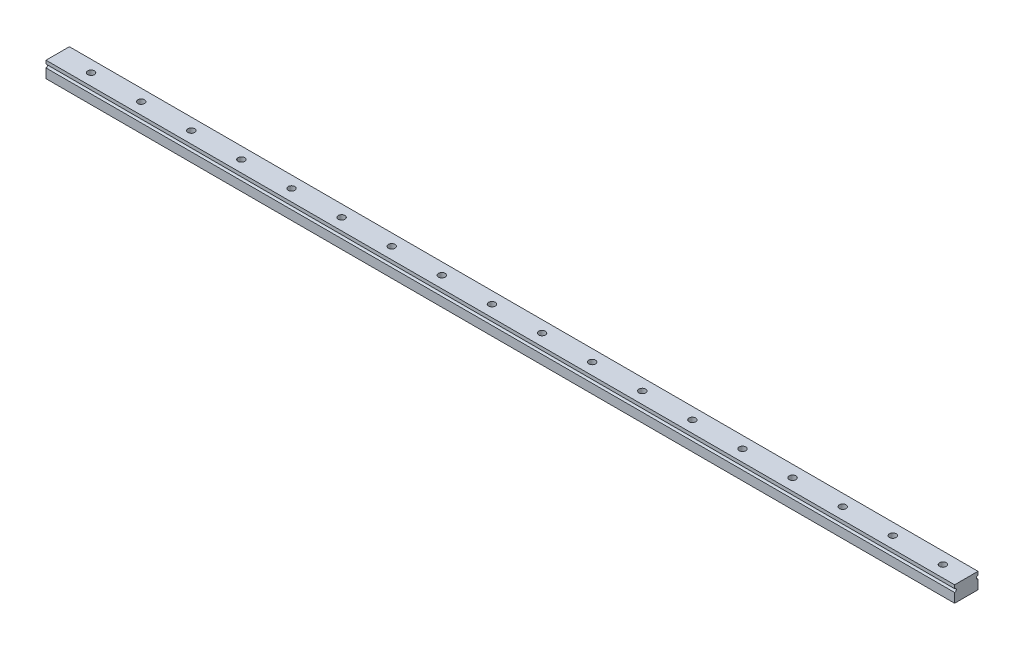
from build123d import *

# Parameters (mm, degrees)
BOSS_EXTRUDE1_DEPTH = 272
SKETCH2_R           = 1
CUT_EXTRUDE1_DEPTH  = 5.8


with BuildPart() as part:
    # Sketch1 → Boss-Extrude1 (new body)
    with BuildSketch(Plane(origin=(0, 0, 0), x_dir=(0, 0, -1), z_dir=(1, 0, 0))):
        with BuildLine():
            Line((3.5, 2.4), (-3.5, 2.4))
            Line((-3.5, 2.4), (-3.5, 1.4))
            ThreePointArc((-3.5, 1.4), (-3.146446609, 1.253553391), (-3, 0.9))
            ThreePointArc((-3, 0.9), (-3.146446609, 0.546446609), (-3.5, 0.4))
            Line((-3.5, 0.4), (-3.5, -2.4))
            Line((-3.5, -2.4), (3.5, -2.4))
            Line((3.5, -2.4), (3.5, 0.4))
            ThreePointArc((3.5, 0.4), (3, 0.9), (3.5, 1.4))
            Line((3.5, 1.4), (3.5, 2.4))
        make_face()
    extrude(amount=BOSS_EXTRUDE1_DEPTH)

    # Sketch2 → Cut-Extrude1 (cut, through all)
    with BuildSketch(Plane(origin=(0, 2.4, 0), x_dir=(1, 0, 0), z_dir=(0, 1, 0))):
        with Locations((10, 0)):
            Circle(SKETCH2_R)
        with Locations((25, 0)):
            Circle(SKETCH2_R)
        with Locations((40, 0)):
            Circle(SKETCH2_R)
        with Locations((55, 0)):
            Circle(SKETCH2_R)
        with Locations((70, 0)):
            Circle(SKETCH2_R)
        with Locations((85, 0)):
            Circle(SKETCH2_R)
        with Locations((100, 0)):
            Circle(SKETCH2_R)
        with Locations((115, 0)):
            Circle(SKETCH2_R)
        with Locations((130, 0)):
            Circle(SKETCH2_R)
        with Locations((145, 0)):
            Circle(SKETCH2_R)
        with Locations((160, 0)):
            Circle(SKETCH2_R)
        with Locations((175, 0)):
            Circle(SKETCH2_R)
        with Locations((190, 0)):
            Circle(SKETCH2_R)
        with Locations((205, 0)):
            Circle(SKETCH2_R)
        with Locations((220, 0)):
            Circle(SKETCH2_R)
        with Locations((235, 0)):
            Circle(SKETCH2_R)
        with Locations((250, 0)):
            Circle(SKETCH2_R)
        with Locations((265, 0)):
            Circle(SKETCH2_R)
        with Locations((280, 0)):
            Circle(SKETCH2_R)
        with Locations((295, 0)):
            Circle(SKETCH2_R)
        with Locations((310, 0)):
            Circle(SKETCH2_R)
        with Locations((325, 0)):
            Circle(SKETCH2_R)
        with Locations((340, 0)):
            Circle(SKETCH2_R)
        with Locations((355, 0)):
            Circle(SKETCH2_R)
        with Locations((370, 0)):
            Circle(SKETCH2_R)
        with Locations((385, 0)):
            Circle(SKETCH2_R)
        with Locations((400, 0)):
            Circle(SKETCH2_R)
        with Locations((415, 0)):
            Circle(SKETCH2_R)
        with Locations((430, 0)):
            Circle(SKETCH2_R)
        with Locations((445, 0)):
            Circle(SKETCH2_R)
        with Locations((460, 0)):
            Circle(SKETCH2_R)
    extrude(amount=-CUT_EXTRUDE1_DEPTH, mode=Mode.SUBTRACT)


solid = part.part
